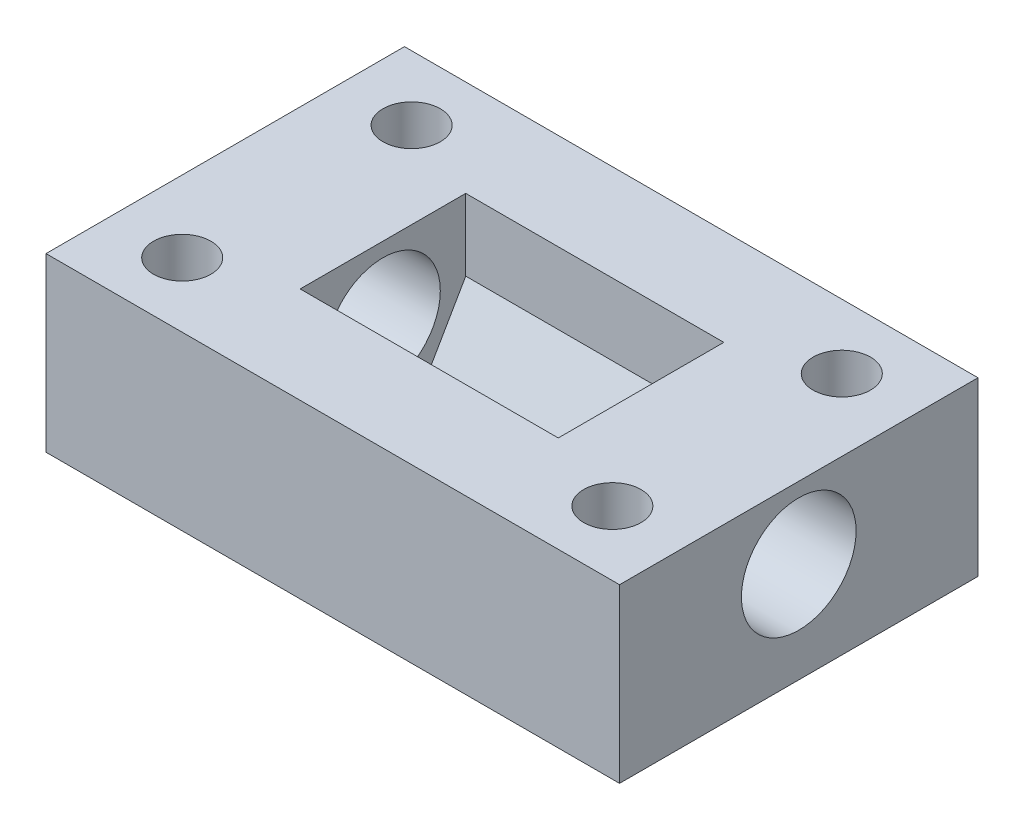
from build123d import *

# Parameters (mm, degrees)
SKETCH1_W               = 40
SKETCH1_H               = 25
BOSS_EXTRUDE1_DEPTH     = 12
CUT_EXTRUDE1_DEPTH      = 9
CUT_EXTRUDE1_DEPTH_BACK = 9
SKETCH3_R               = 4
CUT_EXTRUDE2_DEPTH      = 21
CUT_EXTRUDE2_DEPTH_BACK = 21
SKETCH4_R               = 2
CUT_EXTRUDE3_DEPTH      = 1
CUT_EXTRUDE3_DEPTH_BACK = 13


with BuildPart() as part:
    # Sketch1 → Boss-Extrude1 (new body)
    with BuildSketch(Plane(origin=(0, 0, 0), x_dir=(1, 0, 0), z_dir=(0, 1, 0))):
        Rectangle(SKETCH1_W, SKETCH1_H)
    extrude(amount=BOSS_EXTRUDE1_DEPTH)

    # Sketch2 → Cut-Extrude1 (cut, two sides)
    with BuildSketch(Plane(origin=(0, 0, 0), x_dir=(0, 0, -1), z_dir=(1, 0, 0))) as cut_extrude1_sk:
        Polygon((-2.886751346, 2), (2.886751346, 2), (5.773502692, 7), (5.773502692, 12), (-5.773502692, 12), (-5.773502692, 7), align=None)
    extrude(amount=CUT_EXTRUDE1_DEPTH, mode=Mode.SUBTRACT)
    extrude(cut_extrude1_sk.sketch, amount=-CUT_EXTRUDE1_DEPTH_BACK, mode=Mode.SUBTRACT)

    # Sketch3 → Cut-Extrude2 (cut, two sides)
    with BuildSketch(Plane(origin=(0, 0, 0), x_dir=(0, 0, -1), z_dir=(1, 0, 0))) as cut_extrude2_sk:
        with Locations((0, 7)):
            Circle(SKETCH3_R)
    extrude(amount=CUT_EXTRUDE2_DEPTH, mode=Mode.SUBTRACT)
    extrude(cut_extrude2_sk.sketch, amount=-CUT_EXTRUDE2_DEPTH_BACK, mode=Mode.SUBTRACT)

    # Sketch4 → Cut-Extrude3 (cut, two sides)
    with BuildSketch(Plane(origin=(0, 12, 0), x_dir=(1, 0, 0), z_dir=(0, 1, 0))) as cut_extrude3_sk:
        with Locations((-15, 8)):
            Circle(SKETCH4_R)
        with Locations((15, 8)):
            Circle(SKETCH4_R)
        with Locations((15, -8)):
            Circle(SKETCH4_R)
        with Locations((-15, -8)):
            Circle(SKETCH4_R)
    extrude(amount=CUT_EXTRUDE3_DEPTH, mode=Mode.SUBTRACT)
    extrude(cut_extrude3_sk.sketch, amount=-CUT_EXTRUDE3_DEPTH_BACK, mode=Mode.SUBTRACT)


solid = part.part
